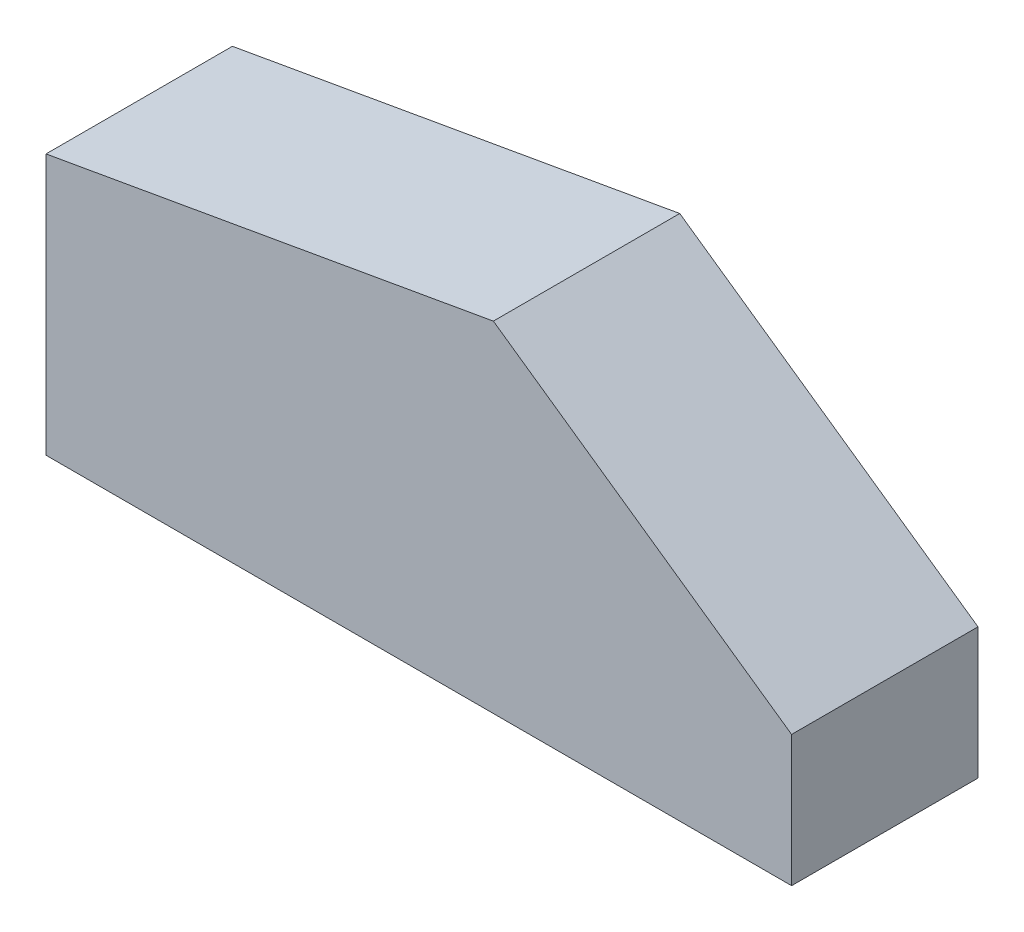
from build123d import *

# Parameters (mm, degrees)
BOSS_EXTRUDE1_DEPTH = 25


with BuildPart() as part:
    # Sketch1 → Boss-Extrude1 (new body)
    with BuildSketch(Plane.XY):
        Polygon((0, 0), (100, 0), (100, 17.571317314), (60, 45.579618843), (0, 35), align=None)
    extrude(amount=BOSS_EXTRUDE1_DEPTH)


solid = part.part
